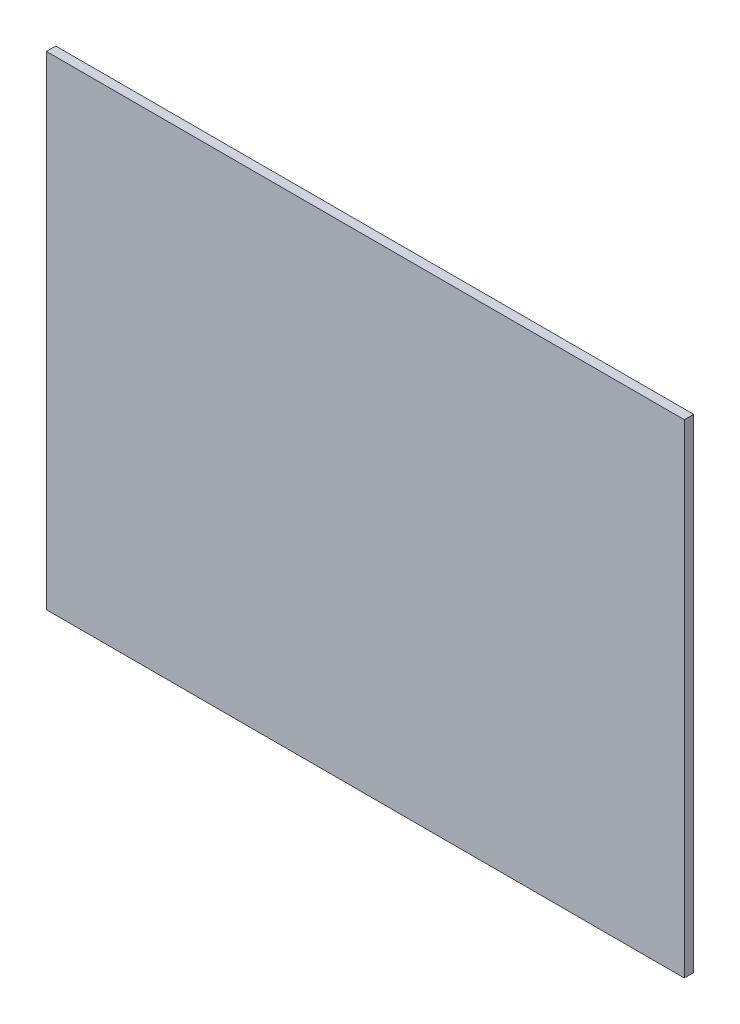
from build123d import *

# Parameters (mm, degrees)
ESQUISSE1_W        = 204.5
ESQUISSE1_H        = 155
BOSS_EXTRU_1_DEPTH = 3


with BuildPart() as part:
    # Esquisse1 → Boss.-Extru.1 (new body)
    with BuildSketch(Plane.XY):
        with Locations((121.732849384, -603.90036528)):
            Rectangle(ESQUISSE1_W, ESQUISSE1_H)
    extrude(amount=BOSS_EXTRU_1_DEPTH)


solid = part.part
